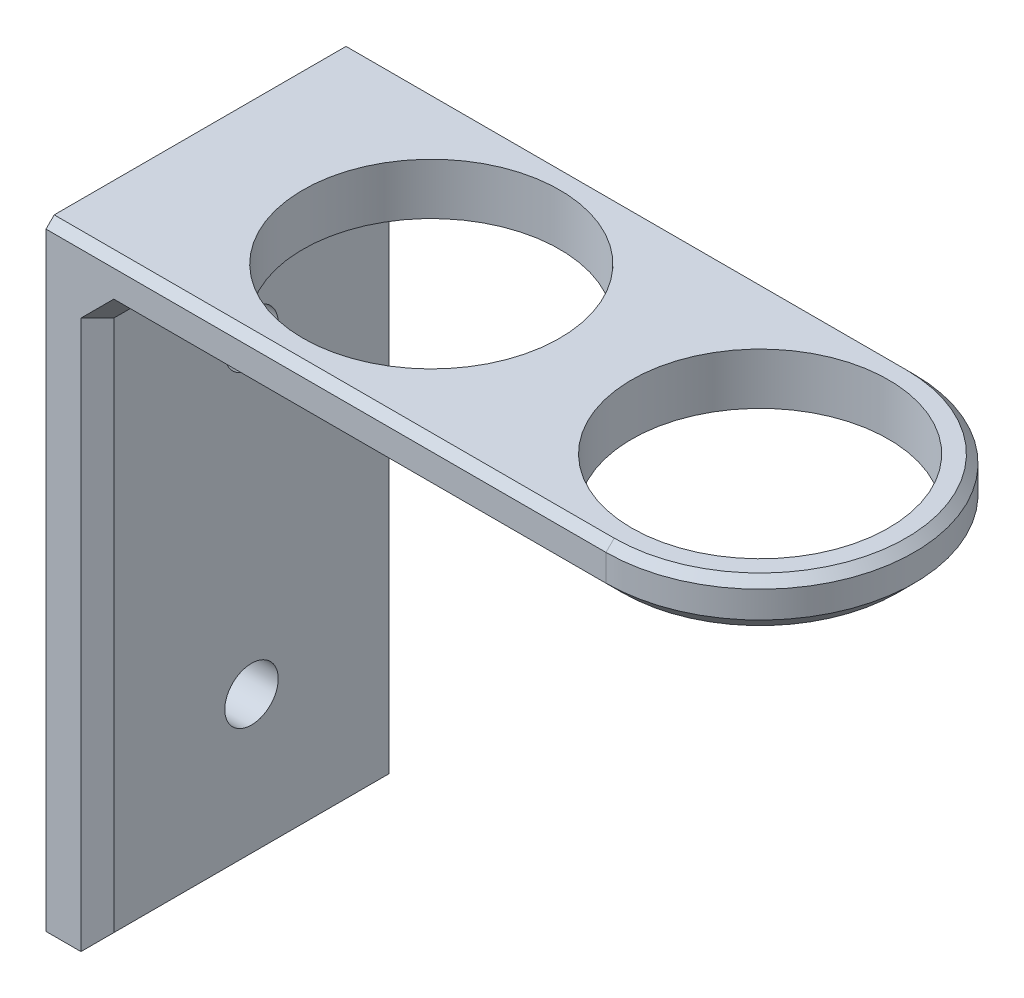
from build123d import *

# Parameters (mm, degrees)
SKETCH1_W           = 38.1
SKETCH1_H           = 38.1
BOSS_EXTRUDE1_DEPTH = 6.35
SKETCH2_R           = 3.302
CUT_EXTRUDE1_DEPTH  = 6.35
SKETCH3_R           = 3.302
CUT_EXTRUDE2_DEPTH  = 6.35
SKETCH4_R           = 15.875
BOSS_EXTRUDE2_DEPTH = 6.35
CHAMFER1_SIZE       = 2.032
CHAMFER2_SIZE       = 1.016


with BuildPart() as part:
    # Sketch1 → Boss-Extrude1 (new body)
    with BuildSketch(Plane(origin=(0, 0, 0), x_dir=(0, 0, -1), z_dir=(1, 0, 0))):
        with Locations((-19.05, 19.05)):
            Rectangle(SKETCH1_W, SKETCH1_H)
        with Locations((-19.05, -19.05)):
            Rectangle(SKETCH1_W, SKETCH1_H)
    extrude(amount=BOSS_EXTRUDE1_DEPTH)

    # Sketch2 → Cut-Extrude1 (cut)
    with BuildSketch(Plane(origin=(6.35, 0, 0), x_dir=(0, 0, -1), z_dir=(1, 0, 0))):
        with Locations((-19.05, -19.05)):
            Circle(SKETCH2_R)
    extrude(amount=-CUT_EXTRUDE1_DEPTH, mode=Mode.SUBTRACT)

    # Sketch3 → Cut-Extrude2 (cut)
    with BuildSketch(Plane(origin=(6.35, 0, 0), x_dir=(0, 0, -1), z_dir=(1, 0, 0))):
        with Locations((-19.05, 19.05)):
            Circle(SKETCH3_R)
    extrude(amount=-CUT_EXTRUDE2_DEPTH, mode=Mode.SUBTRACT)

    # Sketch4 → Boss-Extrude2 (add)
    with BuildSketch(Plane(origin=(0, 38.1, 0), x_dir=(1, 0, 0), z_dir=(0, 1, 0))):
        with BuildLine():
            ThreePointArc((69.215, 0), (88.265, -19.05), (69.215, -38.1))
            Line((69.215, -38.1), (28.575, -38.1))
            Line((28.575, -38.1), (6.35, -38.1))
            Line((6.35, -38.1), (6.35, 0))
            Line((6.35, 0), (28.575, 0))
            Line((28.575, 0), (69.215, 0))
        make_face()
        with Locations((69.215, -19.05)):
            Circle(SKETCH4_R, mode=Mode.SUBTRACT)
        with Locations((28.575, -19.05)):
            Circle(SKETCH4_R, mode=Mode.SUBTRACT)
    extrude(amount=-BOSS_EXTRUDE2_DEPTH)

    # Chamfer1
    chamfer1_edges = [part.edges().sort_by_distance(p)[0] for p in [
        (6.35, -38.1, 19.05),
        (6.35, -3.175, 0),
        (6.35, -3.175, 38.1),
        (37.7825, 31.75, 38.1),
        (88.265, 31.75, 19.05),
        (6.35, 31.75, 19.05),
        (37.7825, 31.75, 0),
    ]]
    chamfer(chamfer1_edges, length=CHAMFER1_SIZE)

    # Chamfer2
    chamfer2_edges = [part.edges().sort_by_distance(p)[0] for p in [
        (34.6075, 38.1, 38.1),
        (88.265, 38.1, 19.05),
        (34.6075, 38.1, 0),
    ]]
    chamfer(chamfer2_edges, length=CHAMFER2_SIZE)


solid = part.part
